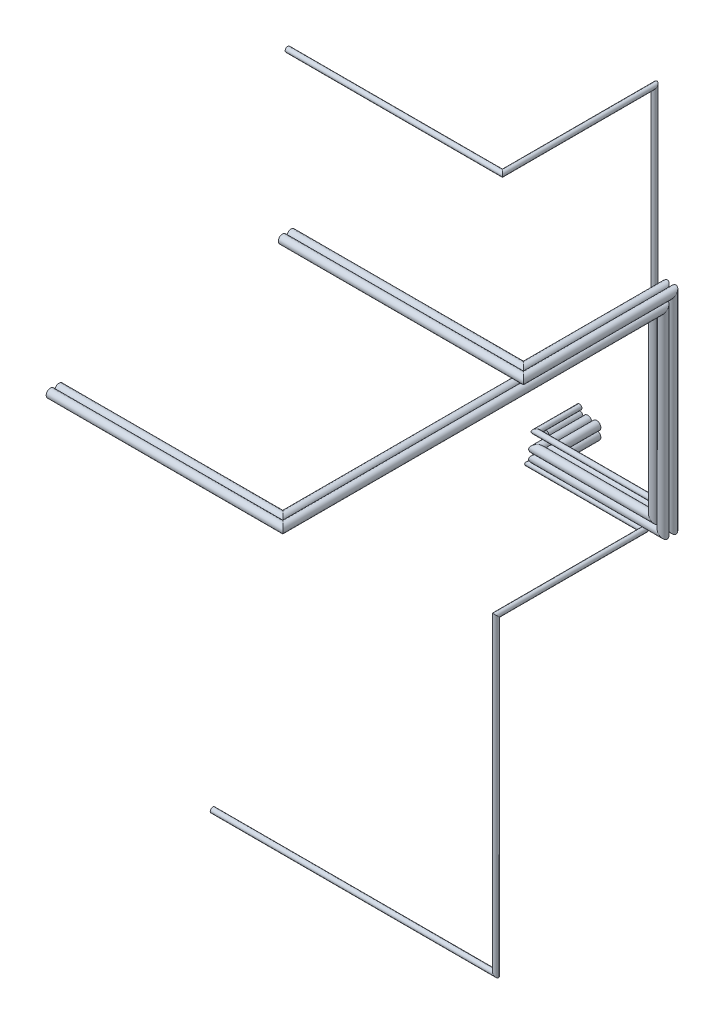
from build123d import *

# Parameters (mm, degrees)
SKETCH1_R             = 50
SKETCH4_R             = 50
BOSS_EXTRUDE1_DEPTH   = 400
BOSS_EXTRUDE1_2_DEPTH = 400
SKETCH5_R             = 30
SKETCH7_R             = 30
SKETCH3_R             = 50
SKETCH2_R             = 50


with BuildPart() as part:
    # Sweep1: sweep along a curve in space
    with BuildLine() as sweep1_path:
        Line((0, 0, 0), (0, 0, 600))
        Line((0, 0, 600), (1490, 0, 600))
        Line((1490, 0, 600), (1490, 2300, 600))
        Line((1490, 2300, 600), (1490, 2300, 2000))
    # Sketch1 → Sweep1 (sweep)
    with BuildSketch(Plane.XY):
        Circle(SKETCH1_R)
        with Locations((104.6202598, 0)):
            Circle(SKETCH1_R)
        with Locations((104.6202598, 101.632314008)):
            Circle(SKETCH1_R)
        with Locations((0, 101.632314008)):
            Circle(SKETCH1_R)
    sweep(path=sweep1_path.line, transition=Transition.RIGHT)

    # Sweep9: sweep along a curve in space
    with BuildLine() as sweep9_path:
        Line((1490, 2300, 2000), (1490, 2300, 5100))
        Line((1490, 2300, 5100), (-1260, 2300, 5100))
    # Sketch3 → Sweep9 (sweep)
    with BuildSketch(Plane.XY.offset(2000)):
        with Locations((1490, 2300)):
            Circle(SKETCH3_R)
        with Locations((1388.367685992, 2300)):
            Circle(SKETCH3_R)
    sweep(path=sweep9_path.line, transition=Transition.RIGHT)

    # Sweep10: sweep along a curve in space
    with BuildLine() as sweep10_path:
        Line((1388.367685992, 2404.6202598, 2000), (1388.367685992, 2404.6202598, 2150))
        Line((1388.367685992, 2404.6202598, 2150), (-1361.632314008, 2404.6202598, 2150))
    # Sketch2 → Sweep10 (sweep)
    with BuildSketch(Plane.XY.offset(2000)):
        with Locations((1490, 2404.6202598)):
            Circle(SKETCH2_R)
        with Locations((1388.367685992, 2404.6202598)):
            Circle(SKETCH2_R)
    sweep(path=sweep10_path.line, transition=Transition.RIGHT)


with BuildPart() as body_2:
    # Sketch4 → Boss-Extrude1 (new body)
    with BuildSketch(Plane(origin=(0, 0, 0), x_dir=(-1, 0, 0), z_dir=(0, 0, -1))):
        with Locations((104.929398094, 0)):
            Circle(SKETCH4_R)
    extrude(amount=-BOSS_EXTRUDE1_DEPTH)


with BuildPart() as body_3:
    # Sketch4 → Boss-Extrude1 2 (new body)
    with BuildSketch(Plane(origin=(0, 0, 0), x_dir=(-1, 0, 0), z_dir=(0, 0, -1))):
        with Locations((104.929398094, 105)):
            Circle(SKETCH4_R)
    extrude(amount=-BOSS_EXTRUDE1_2_DEPTH)


with BuildPart() as body_4:
    # Sweep6: sweep along a curve in space
    with BuildLine() as sweep6_path:
        Line((-99.29220996, -103.996357315, 0), (-99.29220996, -103.996357315, 587.653269417))
        Line((-99.29220996, -103.996357315, 587.653269417), (1250.70779004, -103.996357315, 587.653269417))
        Line((1250.70779004, -103.996357315, 587.653269417), (1250.70779004, -103.996357315, 2337.653269417))
        Line((1250.70779004, -103.996357315, 2337.653269417), (1250.70779004, -3775.40455596, 2337.653269417))
        Line((1250.70779004, -3775.40455596, 2337.653269417), (-2100.967960552, -3775.40455596, 2337.653269417))
    # Sketch5 → Sweep6 (sweep)
    with BuildSketch(Plane(origin=(0, 0, 0), x_dir=(-1, 0, 0), z_dir=(0, 0, -1))):
        with Locations((99.29220996, -103.996357315)):
            Circle(SKETCH5_R)
    sweep(path=sweep6_path.line, transition=Transition.RIGHT)


with BuildPart() as body_5:
    # Sweep8: sweep along a curve in space
    with BuildLine() as sweep8_path:
        Line((-99.29220996, 188.112137483, 0), (-99.29220996, 188.112137483, 510.990772747))
        Line((-99.29220996, 188.112137483, 510.990772747), (1300.70779004, 188.112137483, 510.990772747))
        Line((1300.70779004, 188.112137483, 510.990772747), (1300.70779004, 4438.112137483, 510.990772747))
        Line((1300.70779004, 4438.112137483, 510.990772747), (1300.70779004, 4438.112137483, 2310.990772747))
        Line((1300.70779004, 4438.112137483, 2310.990772747), (-1240.426079734, 4438.112137483, 2310.990772747))
    # Sketch7 → Sweep8 (sweep)
    with BuildSketch(Plane(origin=(0, 0, 0), x_dir=(-1, 0, 0), z_dir=(0, 0, -1))):
        with Locations((99.29220996, 188.112137483)):
            Circle(SKETCH7_R)
    sweep(path=sweep8_path.line, transition=Transition.RIGHT)


solid = Compound([part.part, body_2.part, body_3.part, body_4.part, body_5.part])
